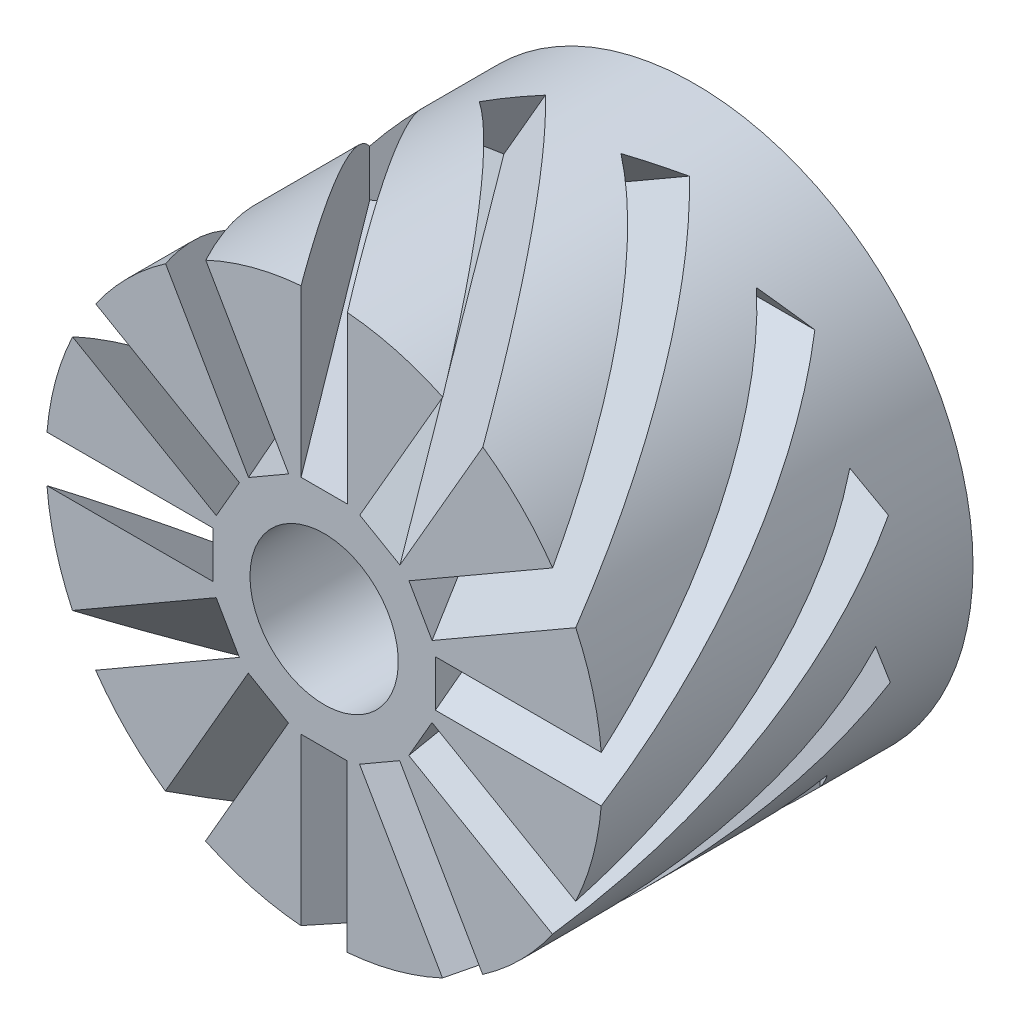
from build123d import *

# Parameters (mm, degrees)
SKETCH2_R           = 4.7625
BOSS_EXTRUDE1_DEPTH = 3.175
SKETCH5_R           = 1.27
CUT_EXTRUDE1_DEPTH  = 7.35
CUT_EXTRUDE2_START  = 1.905
CUT_EXTRUDE2_DEPTH  = 3.8575
CIRPATTERN2_COUNT   = 12


with BuildPart() as part:
    # Sketch2 → Boss-Extrude1 (new body, symmetric)
    with BuildSketch(Plane.XY):
        Circle(SKETCH2_R)
    extrude(amount=BOSS_EXTRUDE1_DEPTH, both=True)

    # Sketch5 → Cut-Extrude1 (cut, through all)
    with BuildSketch(Plane(origin=(0, 0, -3.175), x_dir=(-1, 0, 0), z_dir=(0, 0, -1))):
        Circle(SKETCH5_R)
    extrude(amount=-CUT_EXTRUDE1_DEPTH, mode=Mode.SUBTRACT)

    # Sketch4_2 → Cut-Extrude2 (cut, through all)
    with BuildSketch(Plane(origin=(0, 0, 0), x_dir=(1, 0, 0), z_dir=(0, 1, 0)).offset(CUT_EXTRUDE2_START)):
        with BuildLine():
            Line((-0.108840568, -3.556), (-3.918840568, 1.524))
            Line((-3.918840568, 1.524), (-3.410840568, 1.905))
            Line((-3.410840568, 1.905), (0.399159432, -3.175))
            ThreePointArc((0.399159432, -3.175), (0.335659432, -3.6195), (-0.108840568, -3.556))
        make_face()
    cut_extrude2 = extrude(amount=CUT_EXTRUDE2_DEPTH, mode=Mode.SUBTRACT)

    # CirPattern2: Cut-Extrude2 ×12 about axis
    cirpattern2_axis = Axis((0, 0, 0), (0, 0, 1))
    for i in range(1, CIRPATTERN2_COUNT):
        add(cut_extrude2.rotate(cirpattern2_axis, i * 360 / CIRPATTERN2_COUNT), mode=Mode.SUBTRACT)


solid = part.part
